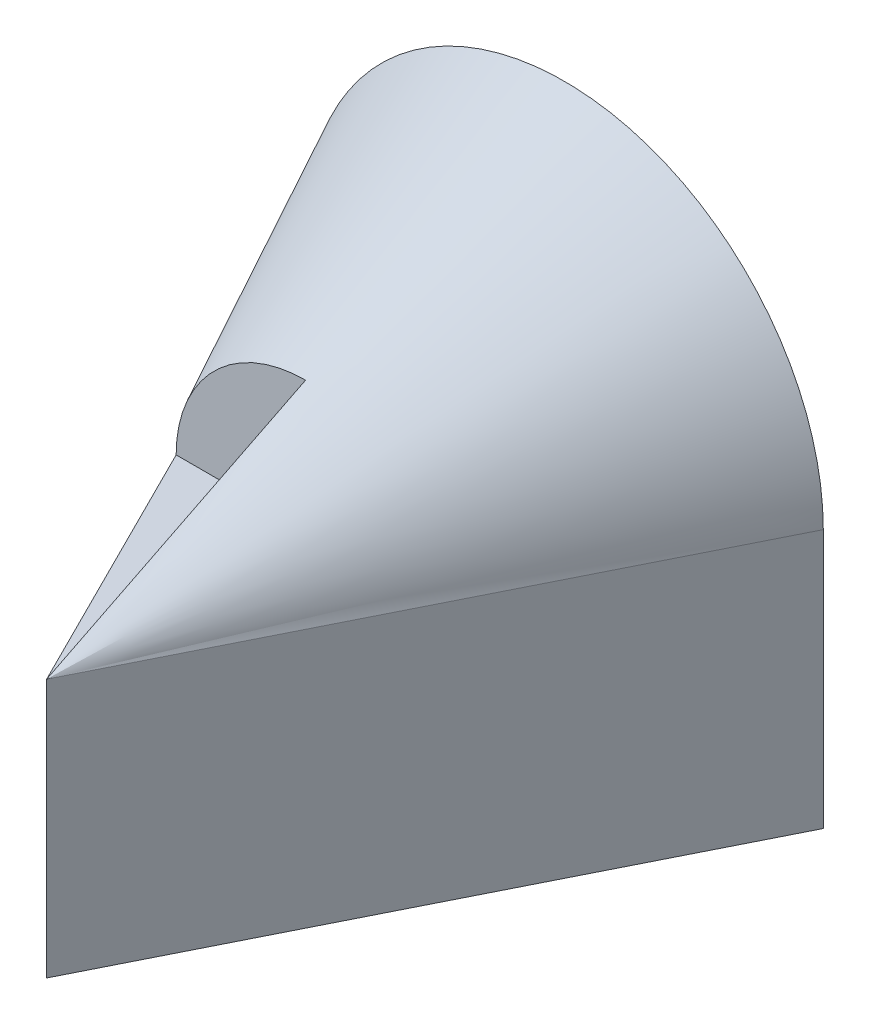
from build123d import *

# Parameters (mm, degrees)
SKETCH1_W           = 40
SKETCH1_H           = 20
BOSS_EXTRUDE1_DEPTH = 40
CUT_EXTRUDE18_DEPTH = 20
CUT_EXTRUDE20_DEPTH = 59
CUT_EXTRUDE21_DEPTH = 59
SKETCH13_W          = 56.232322264
SKETCH13_H          = 131.72647096
CUT_EXTRUDE22_DEPTH = 20
REVOLVE1_ANGLE      = 180
CUT_EXTRUDE23_DEPTH = 20


with BuildPart() as part:
    # Sketch1 → Boss-Extrude1 (new body)
    with BuildSketch(Plane.XY):
        with BuildLine():
            Line((0, 20), (40, 20))
            ThreePointArc((40, 20), (20, 40), (0, 20))
        make_face()
        with Locations((20, 10)):
            Rectangle(SKETCH1_W, SKETCH1_H)
    extrude(amount=BOSS_EXTRUDE1_DEPTH)

    # Sketch4 → Cut-Extrude18 (cut)
    with BuildSketch(Plane.XY.offset(40)):
        with BuildLine():
            Line((20, 30), (20, 20))
            Line((20, 20), (10, 20))
            ThreePointArc((10, 20), (12.928932188, 27.071067812), (20, 30))
        make_face()
    extrude(amount=-CUT_EXTRUDE18_DEPTH, mode=Mode.SUBTRACT)

    # Sketch11 → Cut-Extrude20 (cut)
    with BuildSketch(Plane(origin=(0, 0, 0), x_dir=(1, 0, 0), z_dir=(0, 1, 0))):
        Polygon((20, -40), (0, 0), (0, -40), align=None)
        Polygon((40, 0), (20, -40), (40, -40), align=None)
    extrude(amount=CUT_EXTRUDE20_DEPTH, mode=Mode.SUBTRACT)

    # Sketch12 → Cut-Extrude21 (cut)
    with BuildSketch(Plane(origin=(0, 0, 0), x_dir=(0, 0, -1), z_dir=(1, 0, 0))):
        Polygon((-40, 20), (0, 40), (-40, 40), align=None)
    extrude(amount=CUT_EXTRUDE21_DEPTH, mode=Mode.SUBTRACT)

    # Sketch13 → Cut-Extrude22 (cut)
    with BuildSketch(Plane(origin=(0, 20, 0), x_dir=(1, 0, 0), z_dir=(0, 1, 0))):
        with Locations((25.992745576, -5.369768382)):
            Rectangle(SKETCH13_W, SKETCH13_H)
    extrude(amount=CUT_EXTRUDE22_DEPTH, mode=Mode.SUBTRACT)

    # Sketch14 → Revolve1 (revolve)
    with BuildSketch(Plane(origin=(0, 20, 0), x_dir=(1, 0, 0), z_dir=(0, 1, 0))):
        Polygon((20, -40), (20, 0), (0, 0), align=None)
    revolve(axis=Axis((20, 20, 40), (0, 0, -1)), revolution_arc=REVOLVE1_ANGLE)

    # Sketch15 → Cut-Extrude23 (cut)
    with BuildSketch(Plane(origin=(0, 20, 0), x_dir=(1, 0, 0), z_dir=(0, 1, 0))):
        Polygon((20, -40), (20, -20), (10, -20), align=None)
    extrude(amount=CUT_EXTRUDE23_DEPTH, mode=Mode.SUBTRACT)


solid = part.part
